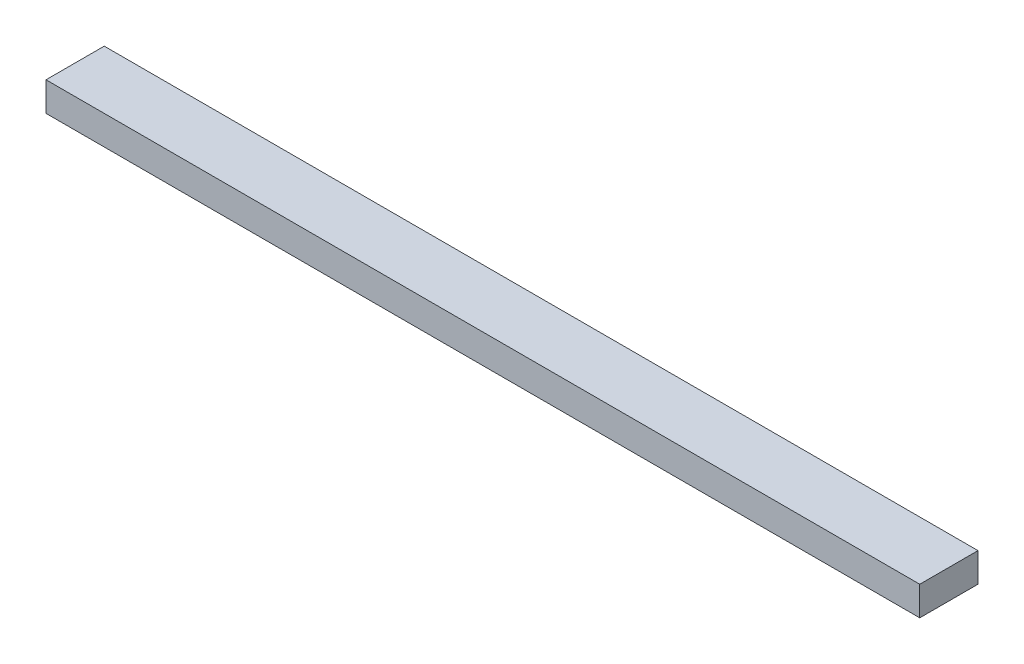
from build123d import *

# Parameters (mm, degrees)
CROQUIS1_W              = 150
CROQUIS1_H              = 10
SALIENTE_EXTRUIR1_DEPTH = 5


with BuildPart() as part:
    # Croquis1 → Saliente-Extruir1 (new body)
    with BuildSketch(Plane(origin=(0, 0, 0), x_dir=(1, 0, 0), z_dir=(0, 1, 0))):
        with Locations((-9.055727554, 10.572755418)):
            Rectangle(CROQUIS1_W, CROQUIS1_H)
    extrude(amount=SALIENTE_EXTRUIR1_DEPTH)


solid = part.part
